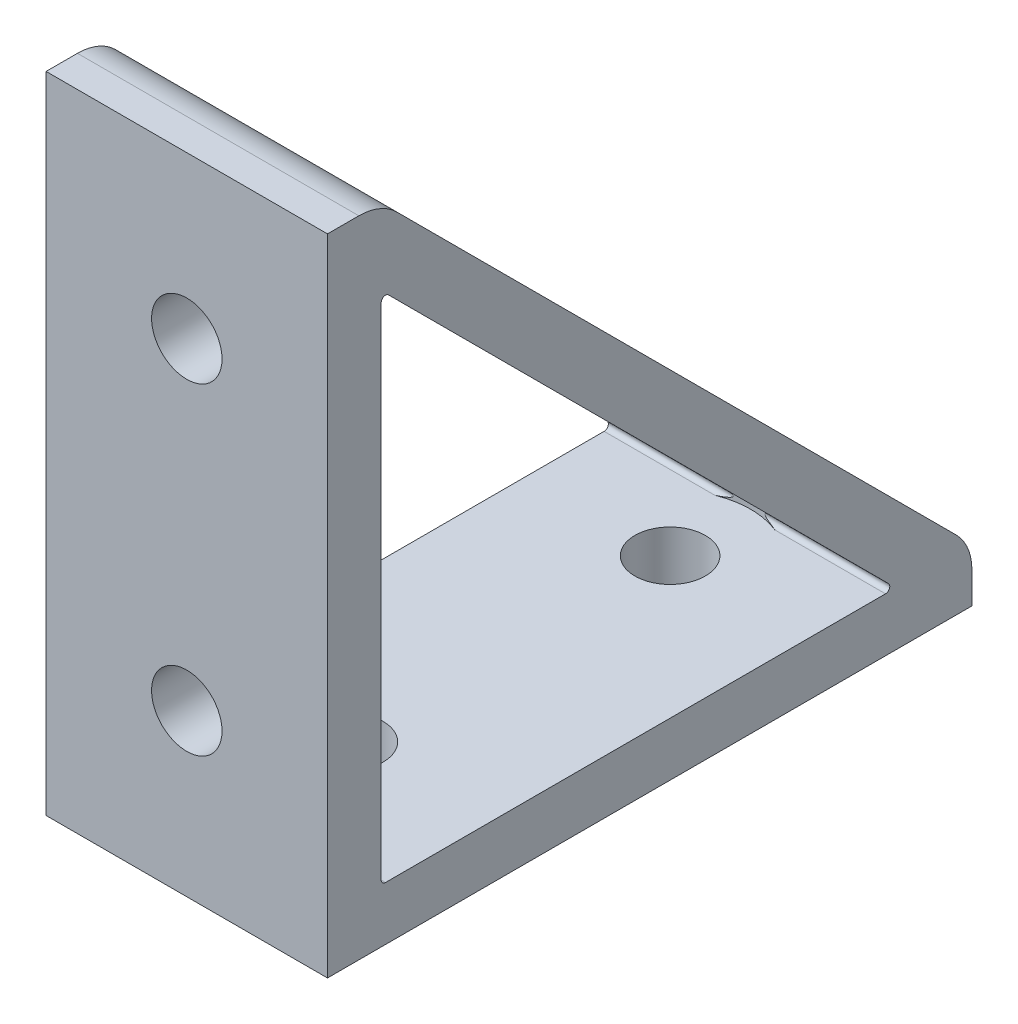
from build123d import *

# Parameters (mm, degrees)
BASE_EXTRUDE_DEPTH       = 33.274
HOLE1_REACH              = 114.783
SKETCH2_R                = 4.1656
SKETCH3_R                = 9.525
HOLE1A_DEPTH             = 109.593838
HOLE1_PATTERN_COUNT      = 2
HOLE1_PATTERN_PITCH      = 38.1
HOLE1_PATTERN_COUNT_DIR2 = 2
HOLE1_PATTERN_PITCH_DIR2 = 38.1
HOLE2_REACH              = 114.783
SKETCH4_R                = 4.1656
SKETCH5_R                = 9.525
HOLE2A_DEPTH             = 109.593838
HOLE2_PATTERN_COUNT      = 2
HOLE2_PATTERN_PITCH      = 38.1
HOLE2_PATTERN_COUNT_DIR2 = 2
HOLE2_PATTERN_PITCH_DIR2 = 38.1


with BuildPart() as part:
    # Sketch1 → Base Extrude (new body)
    with BuildSketch(Plane(origin=(0, 0, 0), x_dir=(0, 0, -1), z_dir=(1, 0, 0))):
        with BuildLine():
            Line((0, 76.2), (0, 0))
            Line((0, 0), (76.2, 0))
            Line((76.2, 0), (76.2, 3.7084))
            ThreePointArc((76.2, 3.7084), (75.716635, 6.13844), (74.340128, 8.198528))
            Line((74.340128, 8.198528), (8.198528, 74.340128))
            ThreePointArc((8.198528, 74.340128), (6.13844, 75.716635), (3.7084, 76.2))
            Line((3.7084, 76.2), (0, 76.2))
        make_face()
        with BuildLine():
            Line((6.35, 65.98198), (6.35, 6.858))
            ThreePointArc((6.35, 6.858), (6.49879, 6.49879), (6.858, 6.35))
            Line((6.858, 6.35), (65.98198, 6.35))
            ThreePointArc((65.98198, 6.35), (66.45131, 6.663597), (66.34119, 7.21721))
            Line((66.34119, 7.21721), (7.21721, 66.34119))
            ThreePointArc((7.21721, 66.34119), (6.663597, 66.45131), (6.35, 65.98198))
        make_face(mode=Mode.SUBTRACT)
    extrude(amount=-BASE_EXTRUDE_DEPTH)

    # Sketch2 → Hole1 (cut, up to next)
    with BuildSketch(Plane.XZ, mode=Mode.PRIVATE) as hole1_sk1:
        with Locations(Location((-16.637, -19.05, 0), (0, 0, 270))):
            Circle(SKETCH2_R)
    hole1_tool1 = extrude(hole1_sk1.sketch, amount=-HOLE1_REACH, mode=Mode.PRIVATE) & part.part
    hole1 = hole1_tool1.solids().sort_by_distance((-16.637, 0, -19.05))[0]
    add(hole1, mode=Mode.SUBTRACT)

    # Sketch3 → Hole1a (cut, through all)
    with BuildSketch(Plane(origin=(0, 6.35, 0), x_dir=(-1, 0, 0), z_dir=(0, 1, 0))):
        with Locations(Location((16.637, -19.05, 0), (0, 0, 270))):
            Circle(SKETCH3_R)
    hole1a = extrude(amount=HOLE1A_DEPTH, mode=Mode.SUBTRACT)

    # Hole1 Pattern: Hole1, Hole1a 2 × 2
    with Locations(*[(i * HOLE1_PATTERN_PITCH, 0, -j * HOLE1_PATTERN_PITCH_DIR2) for i in range(HOLE1_PATTERN_COUNT) for j in range(HOLE1_PATTERN_COUNT_DIR2) if (i, j) != (0, 0)]):
        add(hole1, mode=Mode.SUBTRACT)
        add(hole1a, mode=Mode.SUBTRACT)

    # Sketch4 → Hole2 (cut, up to next)
    with BuildSketch(Plane.XY, mode=Mode.PRIVATE) as hole2_sk1:
        with Locations((-16.637, 19.05)):
            Circle(SKETCH4_R)
    hole2_tool1 = extrude(hole2_sk1.sketch, amount=-HOLE2_REACH, mode=Mode.PRIVATE) & part.part
    hole2 = hole2_tool1.solids().sort_by_distance((-16.637, 19.05, 0))[0]
    add(hole2, mode=Mode.SUBTRACT)

    # Sketch5 → Hole2a (cut, through all)
    with BuildSketch(Plane(origin=(0, 0, -6.35), x_dir=(-1, 0, 0), z_dir=(0, 0, -1))):
        with Locations((16.637, 19.05)):
            Circle(SKETCH5_R)
    hole2a = extrude(amount=HOLE2A_DEPTH, mode=Mode.SUBTRACT)

    # Hole2 Pattern: Hole2, Hole2a 2 × 2
    with Locations(*[(i * HOLE2_PATTERN_PITCH, j * HOLE2_PATTERN_PITCH_DIR2, 0) for i in range(HOLE2_PATTERN_COUNT) for j in range(HOLE2_PATTERN_COUNT_DIR2) if (i, j) != (0, 0)]):
        add(hole2, mode=Mode.SUBTRACT)
        add(hole2a, mode=Mode.SUBTRACT)


solid = part.part
